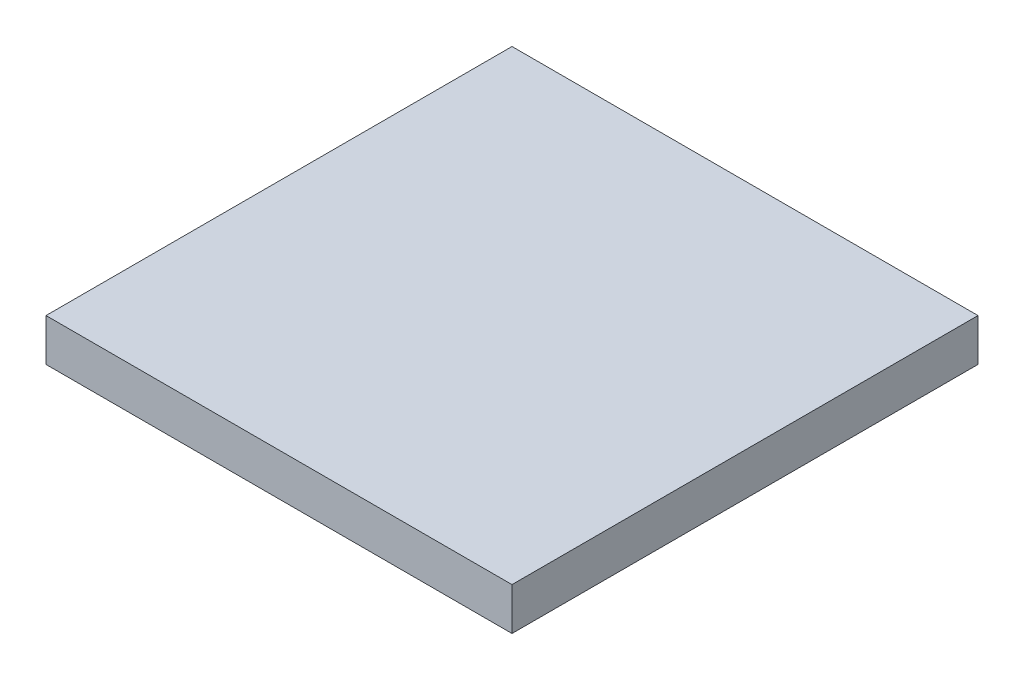
from build123d import *

# Parameters (mm, degrees)
SKETCH1_W           = 550
SKETCH1_H           = 550
BOSS_EXTRUDE1_DEPTH = 50


with BuildPart() as part:
    # Sketch1 → Boss-Extrude1 (new body)
    with BuildSketch(Plane(origin=(0, 0, 0), x_dir=(1, 0, 0), z_dir=(0, 1, 0))):
        with Locations((275, 275)):
            Rectangle(SKETCH1_W, SKETCH1_H)
    extrude(amount=BOSS_EXTRUDE1_DEPTH)


solid = part.part
